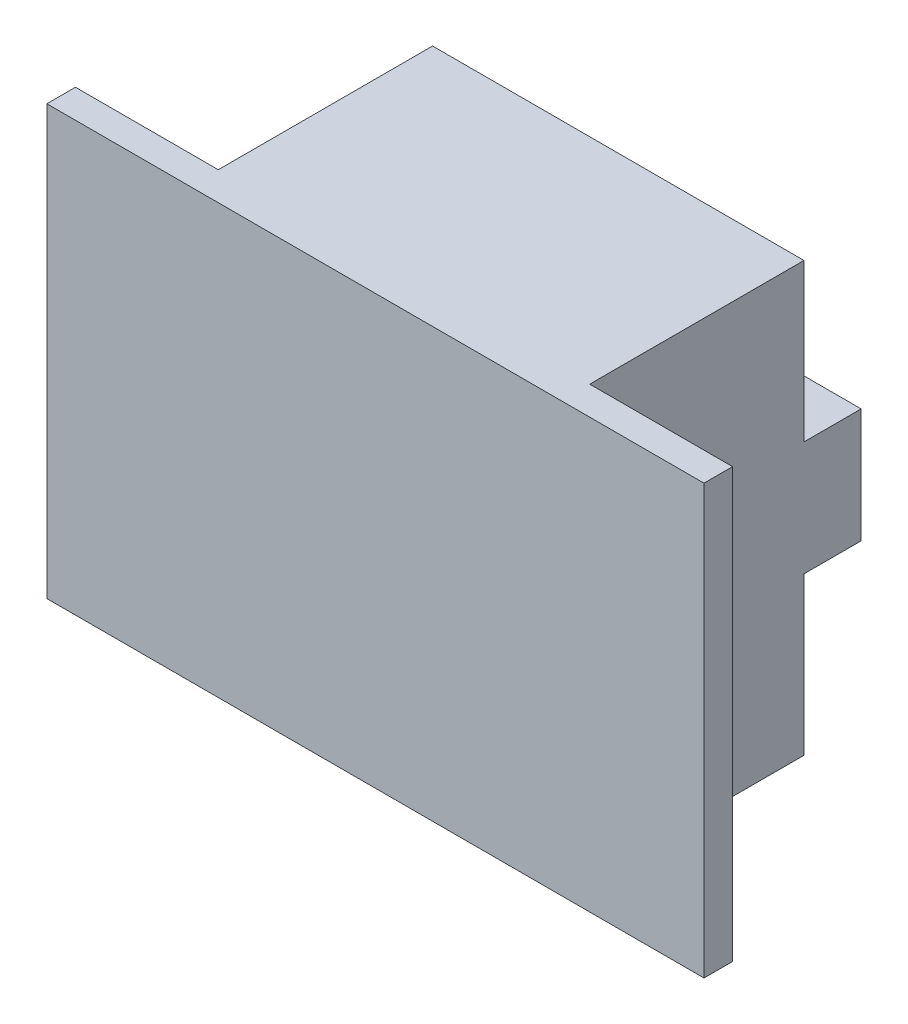
from build123d import *

# Parameters (mm, degrees)
SKETCH_1_W      = 26
SKETCH_1_H      = 30
EXTRUDE_1_DEPTH = 15
SKETCH_2_W      = 46
SKETCH_2_H      = 30
EXTRUDE_2_DEPTH = 2
SKETCH_4_W      = 26
SKETCH_4_H      = 8
EXTRUDE_3_DEPTH = 4


with BuildPart() as part:
    # 草图1 → 凸台-拉伸1 (new body)
    with BuildSketch(Plane.XY):
        with Locations((-460, 0)):
            Rectangle(SKETCH_1_W, SKETCH_1_H)
    extrude(amount=EXTRUDE_1_DEPTH)

    # 草图2 → 凸台-拉伸2 (add)
    with BuildSketch(Plane.XY.offset(15)):
        with Locations((-460, 0)):
            Rectangle(SKETCH_2_W, SKETCH_2_H)
    extrude(amount=EXTRUDE_2_DEPTH)

    # 草图4 → 凸台-拉伸3 (add)
    with BuildSketch(Plane(origin=(0, 0, 0), x_dir=(-1, 0, 0), z_dir=(0, 0, -1))):
        with Locations((460, 0)):
            Rectangle(SKETCH_4_W, SKETCH_4_H)
    extrude(amount=EXTRUDE_3_DEPTH)


solid = part.part
